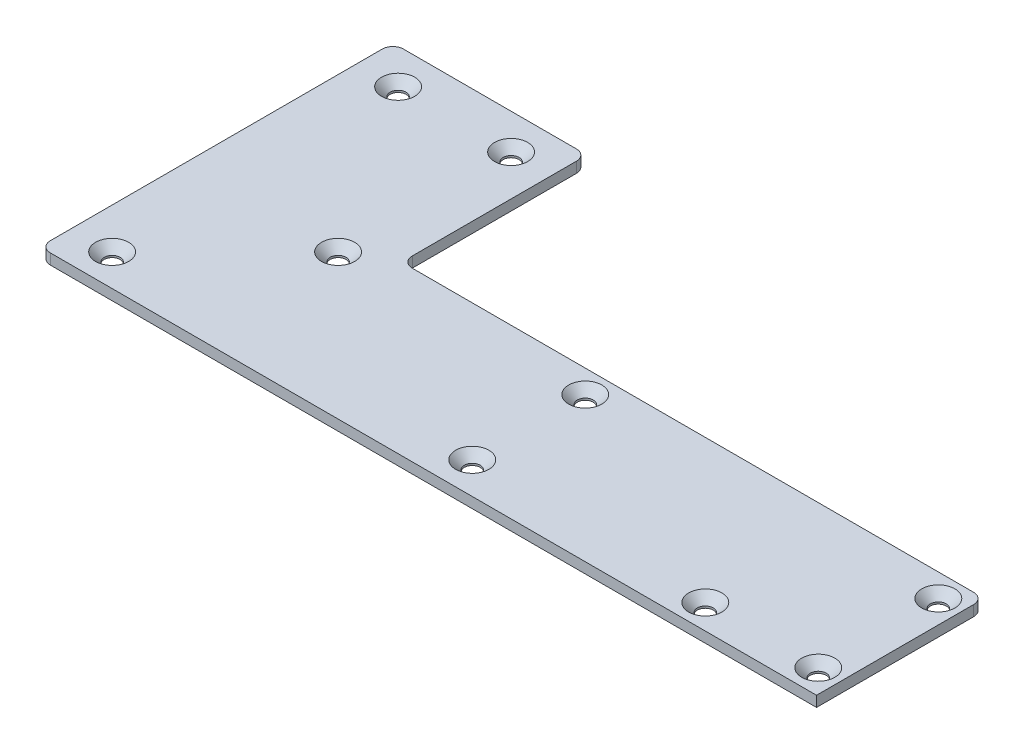
from build123d import *

# Parameters (mm, degrees)
EXTRUDE1_DEPTH                               = 3
CSK_FOR_M4_COUNTERSUNK_FLAT_HEAD_SCR_2_COUNT = 2
CSK_FOR_M4_COUNTERSUNK_FLAT_HEAD_SCR_2_PITCH = 81
CSK_FOR_M4_COUNTERSUNK_FLAT_HEAD_SCR_3_COUNT = 2
CSK_FOR_M4_COUNTERSUNK_FLAT_HEAD_SCR_3_PITCH = 58.523499554
CSK_FOR_M4_COUNTERSUNK_FLAT_HEAD_SCR_4_COUNT = 2
CSK_FOR_M4_COUNTERSUNK_FLAT_HEAD_SCR_4_PITCH = 32
CSK_FOR_M4_COUNTERSUNK_FLAT_HEAD_SCR_5_COUNT = 2
CSK_FOR_M4_COUNTERSUNK_FLAT_HEAD_SCR_5_PITCH = 113.159179919
CSK_FOR_M4_COUNTERSUNK_FLAT_HEAD_SCR_6_COUNT = 2
CSK_FOR_M4_COUNTERSUNK_FLAT_HEAD_SCR_6_PITCH = 130.249760077
CSK_FOR_M4_COUNTERSUNK_FLAT_HEAD_SCR_7_COUNT = 2
CSK_FOR_M4_COUNTERSUNK_FLAT_HEAD_SCR_7_PITCH = 189.179808648
CSK_FOR_M4_COUNTERSUNK_FLAT_HEAD_SCR_8_COUNT = 2
CSK_FOR_M4_COUNTERSUNK_FLAT_HEAD_SCR_8_PITCH = 218.387270691
CSK_FOR_M4_COUNTERSUNK_FLAT_HEAD_SCR_9_COUNT = 2
CSK_FOR_M4_COUNTERSUNK_FLAT_HEAD_SCR_9_PITCH = 207.858124691
FILLET1_R                                    = 3


with BuildPart() as part:
    # Sketch1 → Extrude1 (new body)
    with BuildSketch(Plane(origin=(0, 0, 0), x_dir=(1, 0, 0), z_dir=(0, 1, 0))):
        Polygon((0, 0), (220, 0), (220, 47.5), (55, 47.5), (55, 100), (0, 100), align=None)
    extrude(amount=EXTRUDE1_DEPTH)

    # Sketch3 → CSK for M4 Countersunk Flat Head Screw1 (revolve, cut)
    with BuildSketch(Plane(origin=(11.5, 3, -90), x_dir=(0, 0, 1), z_dir=(1, 0, 0))):
        Polygon((0, 0), (0, 3), (2.25, 3), (2.25, 2.45), (4.7, 0), align=None)
    csk_for_m4_countersunk_flat_head_screw1 = revolve(axis=Axis((11.5, 9.35, -90), (0, -1, 0)), mode=Mode.SUBTRACT)

    # CSK for M4 Countersunk Flat Head Scr 2: CSK for M4 Countersunk Flat Head Screw1 ×2
    with Locations(*[(0, 0, i * CSK_FOR_M4_COUNTERSUNK_FLAT_HEAD_SCR_2_PITCH) for i in range(1, CSK_FOR_M4_COUNTERSUNK_FLAT_HEAD_SCR_2_COUNT)]):
        add(csk_for_m4_countersunk_flat_head_screw1, mode=Mode.SUBTRACT)

    # CSK for M4 Countersunk Flat Head Scr 3: CSK for M4 Countersunk Flat Head Screw1 ×2
    with Locations(*[Vector(0.546788901, 0, 0.837270505) * (i * CSK_FOR_M4_COUNTERSUNK_FLAT_HEAD_SCR_3_PITCH) for i in range(1, CSK_FOR_M4_COUNTERSUNK_FLAT_HEAD_SCR_3_COUNT)]):
        add(csk_for_m4_countersunk_flat_head_screw1, mode=Mode.SUBTRACT)

    # CSK for M4 Countersunk Flat Head Scr 4: CSK for M4 Countersunk Flat Head Screw1 ×2
    with Locations(*[(i * CSK_FOR_M4_COUNTERSUNK_FLAT_HEAD_SCR_4_PITCH, 0, 0) for i in range(1, CSK_FOR_M4_COUNTERSUNK_FLAT_HEAD_SCR_4_COUNT)]):
        add(csk_for_m4_countersunk_flat_head_screw1, mode=Mode.SUBTRACT)

    # CSK for M4 Countersunk Flat Head Scr 5: CSK for M4 Countersunk Flat Head Screw1 ×2
    with Locations(*[Vector(0.901385111, 0, 0.433018338) * (i * CSK_FOR_M4_COUNTERSUNK_FLAT_HEAD_SCR_5_PITCH) for i in range(1, CSK_FOR_M4_COUNTERSUNK_FLAT_HEAD_SCR_5_COUNT)]):
        add(csk_for_m4_countersunk_flat_head_screw1, mode=Mode.SUBTRACT)

    # CSK for M4 Countersunk Flat Head Scr 6: CSK for M4 Countersunk Flat Head Screw1 ×2
    with Locations(*[Vector(0.783110847, 0, 0.621882144) * (i * CSK_FOR_M4_COUNTERSUNK_FLAT_HEAD_SCR_6_PITCH) for i in range(1, CSK_FOR_M4_COUNTERSUNK_FLAT_HEAD_SCR_6_COUNT)]):
        add(csk_for_m4_countersunk_flat_head_screw1, mode=Mode.SUBTRACT)

    # CSK for M4 Countersunk Flat Head Scr 7: CSK for M4 Countersunk Flat Head Screw1 ×2
    with Locations(*[Vector(0.898615985, 0, 0.43873604) * (i * CSK_FOR_M4_COUNTERSUNK_FLAT_HEAD_SCR_7_PITCH) for i in range(1, CSK_FOR_M4_COUNTERSUNK_FLAT_HEAD_SCR_7_COUNT)]):
        add(csk_for_m4_countersunk_flat_head_screw1, mode=Mode.SUBTRACT)

    # CSK for M4 Countersunk Flat Head Scr 8: CSK for M4 Countersunk Flat Head Screw1 ×2
    with Locations(*[Vector(0.924962336, 0, 0.380058782) * (i * CSK_FOR_M4_COUNTERSUNK_FLAT_HEAD_SCR_8_PITCH) for i in range(1, CSK_FOR_M4_COUNTERSUNK_FLAT_HEAD_SCR_8_COUNT)]):
        add(csk_for_m4_countersunk_flat_head_screw1, mode=Mode.SUBTRACT)

    # CSK for M4 Countersunk Flat Head Scr 9: CSK for M4 Countersunk Flat Head Screw1 ×2
    with Locations(*[Vector(0.971816715, 0, 0.235737718) * (i * CSK_FOR_M4_COUNTERSUNK_FLAT_HEAD_SCR_9_PITCH) for i in range(1, CSK_FOR_M4_COUNTERSUNK_FLAT_HEAD_SCR_9_COUNT)]):
        add(csk_for_m4_countersunk_flat_head_screw1, mode=Mode.SUBTRACT)

    # Fillet1
    fillet1_edges = [part.edges().sort_by_distance(p)[0] for p in [
        (0, 1.5, -100),
        (55, 1.5, -100),
        (55, 1.5, -47.5),
        (220, 1.5, -47.5),
        (0, 1.5, 0),
    ]]
    fillet(fillet1_edges, radius=FILLET1_R)


solid = part.part
